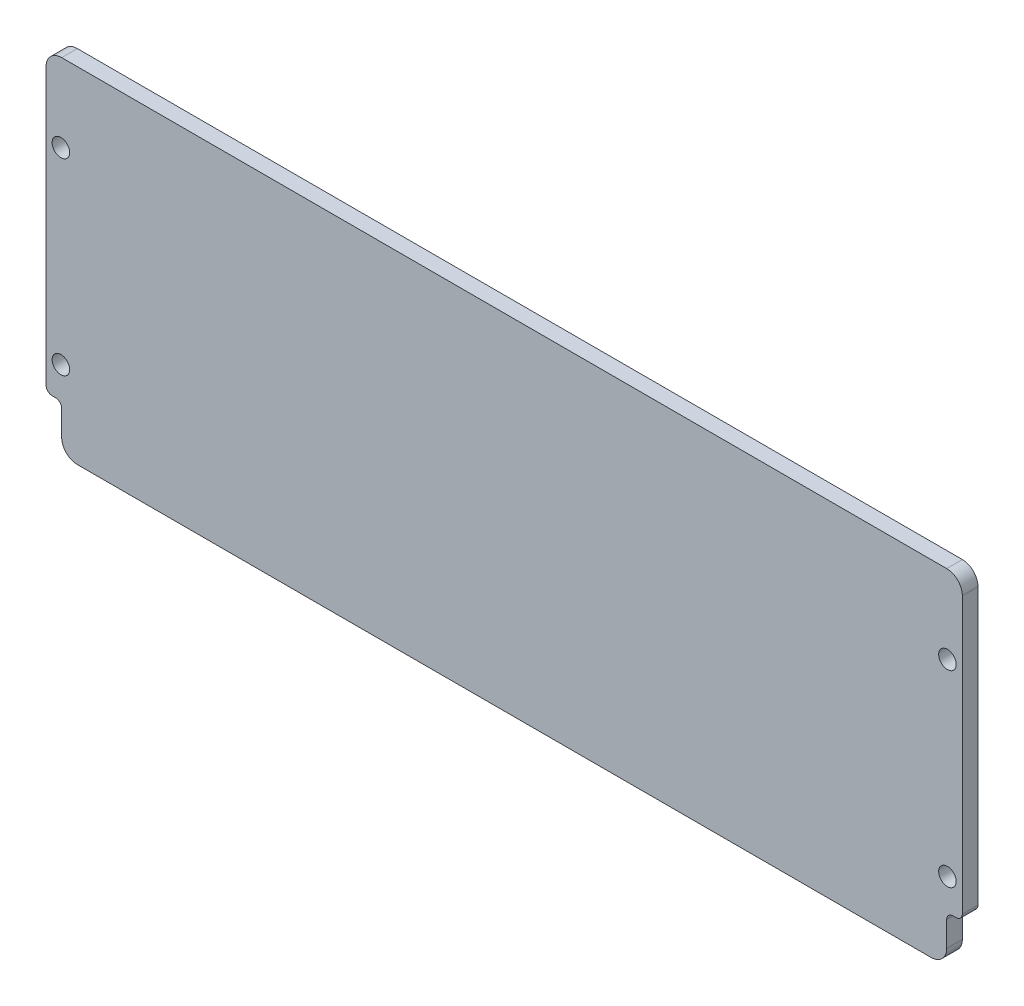
from build123d import *

# Parameters (mm, degrees)
SKETCH1_R           = 3.556
BOSS_EXTRUDE1_DEPTH = 6.35


with BuildPart() as part:
    # Sketch1 → Boss-Extrude1 (new body)
    with BuildSketch(Plane.XY):
        with BuildLine():
            Line((-185.7375, 133.35), (-185.7375, 21.59))
            ThreePointArc((-185.7375, 21.59), (-184.993551224, 19.793948776), (-183.1975, 19.05))
            Line((-183.1975, 19.05), (-181.9275, 19.05))
            ThreePointArc((-181.9275, 19.05), (-180.131448776, 18.306051224), (-179.3875, 16.51))
            Line((-179.3875, 16.51), (-179.3875, 6.35))
            ThreePointArc((-179.3875, 6.35), (-177.527628061, 1.859871939), (-173.0375, 0))
            Line((-173.0375, 0), (173.0375, 0))
            ThreePointArc((173.0375, 0), (177.527628061, 1.859871939), (179.3875, 6.35))
            Line((179.3875, 6.35), (179.3875, 16.51))
            ThreePointArc((179.3875, 16.51), (180.131448776, 18.306051224), (181.9275, 19.05))
            Line((181.9275, 19.05), (183.1975, 19.05))
            ThreePointArc((183.1975, 19.05), (184.993551224, 19.793948776), (185.7375, 21.59))
            Line((185.7375, 21.59), (185.7375, 133.35))
            ThreePointArc((185.7375, 133.35), (183.877628061, 137.840128061), (179.3875, 139.7))
            Line((179.3875, 139.7), (-179.3875, 139.7))
            ThreePointArc((-179.3875, 139.7), (-183.877628061, 137.840128061), (-185.7375, 133.35))
        make_face()
        with Locations((-179.705, 31.75)):
            Circle(SKETCH1_R, mode=Mode.SUBTRACT)
        with Locations((-179.705, 107.95)):
            Circle(SKETCH1_R, mode=Mode.SUBTRACT)
        with Locations((179.705, 107.95)):
            Circle(SKETCH1_R, mode=Mode.SUBTRACT)
        with Locations((179.705, 31.75)):
            Circle(SKETCH1_R, mode=Mode.SUBTRACT)
    extrude(amount=BOSS_EXTRUDE1_DEPTH)


solid = part.part
